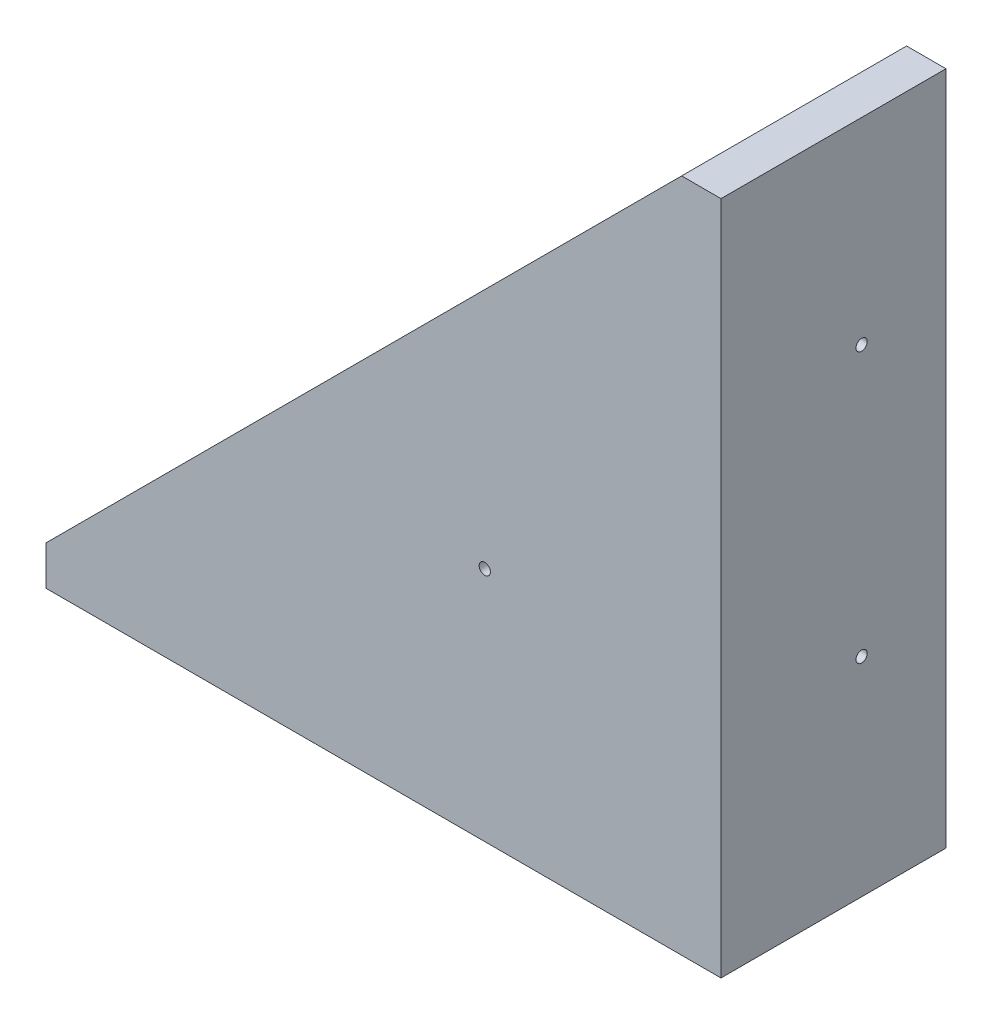
from build123d import *

# Parameters (mm, degrees)
ESQUISSE1_W             = 7
ESQUISSE1_H             = 113
ESQUISSE1_W_2           = 120
ESQUISSE1_H_2           = 7
BOSS_EXTRU_2_DEPTH      = 40
ESQUISSE4_W             = 113
ESQUISSE4_H             = 10
BOSS_EXTRU_8_DEPTH      = 115
ENL_V_MAT_EXTRU_2_DEPTH = 115
ESQUISSE2_R             = 1
ENL_V_MAT_EXTRU_4_DEPTH = 115
ESQUISSE7_R             = 1
ENL_V_MAT_EXTRU_5_DEPTH = 115
ESQUISSE8_R             = 1
ENL_V_MAT_EXTRU_6_DEPTH = 115
ESQUISSE9_R             = 1
ENL_V_MAT_EXTRU_7_DEPTH = 115
ESQUISSE10_R            = 1
ENL_V_MAT_EXTRU_8_DEPTH = 20


with BuildPart() as part:
    # Esquisse1 → Boss.-Extru.2 (new body)
    with BuildSketch(Plane.XY):
        with Locations((23.75751598, 59.836675468)):
            Rectangle(ESQUISSE1_W, ESQUISSE1_H)
        with Locations((-32.74248402, -0.163324532)):
            Rectangle(ESQUISSE1_W_2, ESQUISSE1_H_2)
    extrude(amount=BOSS_EXTRU_2_DEPTH)

    # Esquisse4 → Boss.-Extru.8 (add)
    with BuildSketch(Plane(origin=(0, 3.336675468, 0), x_dir=(1, 0, 0), z_dir=(0, 1, 0))):
        with Locations((-36.24248402, -35)):
            Rectangle(ESQUISSE4_W, ESQUISSE4_H)
    extrude(amount=BOSS_EXTRU_8_DEPTH)

    # Esquisse6 → Enlèv. mat.-Extru.2 (cut)
    with BuildSketch(Plane.XY.offset(40)):
        Polygon((20.25751598, 116.336675468), (-92.74248402, 3.336675468), (-92.74248402, 118.336675468), (20.25751598, 118.336675468), align=None)
    extrude(amount=-ENL_V_MAT_EXTRU_2_DEPTH, mode=Mode.SUBTRACT)

    # Esquisse2 → Enlèv. mat.-Extru.4 (cut)
    with BuildSketch(Plane(origin=(0, 3.336675468, 0), x_dir=(1, 0, 0), z_dir=(0, 1, 0))):
        with Locations(Location((-57.74248402, -15, 0), (0, 0, 180))):  # turned: the seam where the file's is
            Circle(ESQUISSE2_R)
    extrude(amount=-ENL_V_MAT_EXTRU_4_DEPTH, mode=Mode.SUBTRACT)

    # Esquisse7 → Enlèv. mat.-Extru.5 (cut)
    with BuildSketch(Plane(origin=(0, 3.336675468, 0), x_dir=(1, 0, 0), z_dir=(0, 1, 0))):
        with Locations(Location((-9.74248402, -15, 0), (0, 0, 180))):  # turned: the seam where the file's is
            Circle(ESQUISSE7_R)
    extrude(amount=-ENL_V_MAT_EXTRU_5_DEPTH, mode=Mode.SUBTRACT)

    # Esquisse8 → Enlèv. mat.-Extru.6 (cut)
    with BuildSketch(Plane.ZY.offset(-20.25751598)):
        with Locations((15, 81.336675468)):
            Circle(ESQUISSE8_R)
    extrude(amount=-ENL_V_MAT_EXTRU_6_DEPTH, mode=Mode.SUBTRACT)

    # Esquisse9 → Enlèv. mat.-Extru.7 (cut)
    with BuildSketch(Plane.ZY.offset(-20.25751598)):
        with Locations((15, 33.336675468)):
            Circle(ESQUISSE9_R)
    extrude(amount=-ENL_V_MAT_EXTRU_7_DEPTH, mode=Mode.SUBTRACT)

    # Esquisse10 → Enlèv. mat.-Extru.8 (cut)
    with BuildSketch(Plane(origin=(0, 0, 30), x_dir=(-1, 0, 0), z_dir=(0, 0, -1))):
        with Locations((14.74248402, 38.336675468)):
            Circle(ESQUISSE10_R)
    extrude(amount=-ENL_V_MAT_EXTRU_8_DEPTH, mode=Mode.SUBTRACT)


solid = part.part
